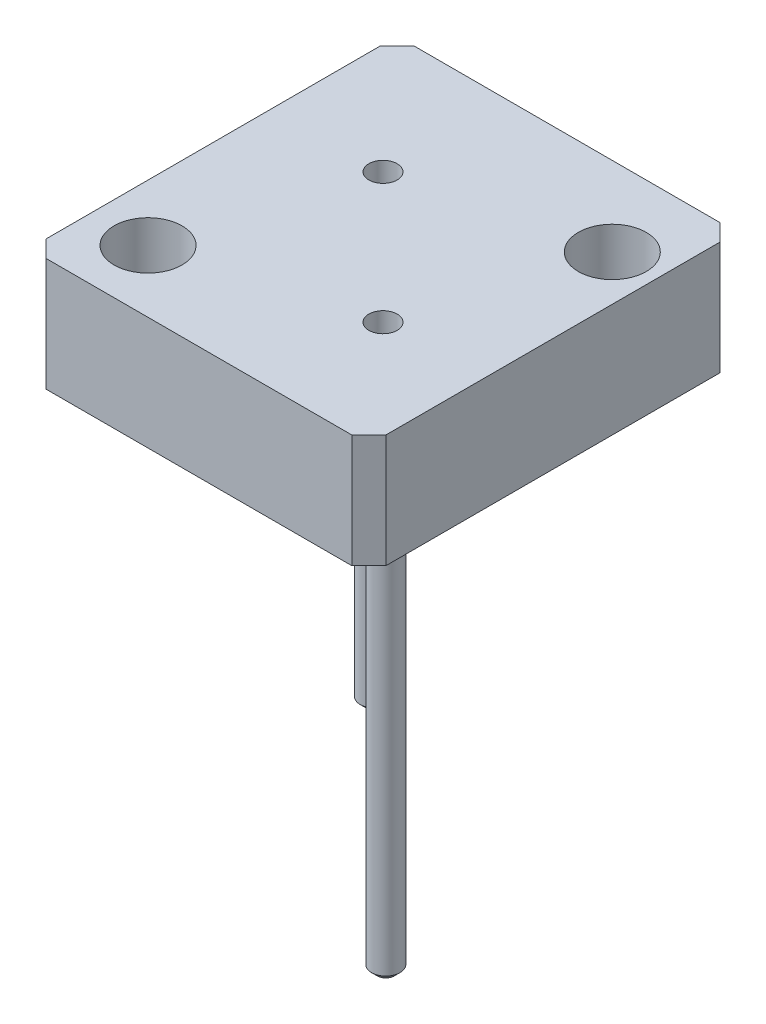
from build123d import *

# Parameters (mm, degrees)
SKETCH1_W           = 60
SKETCH1_H           = 65
BOSS_EXTRUDE1_DEPTH = 20
SKETCH2_R           = 6
CUT_EXTRUDE1_DEPTH  = 91.691785736
SKETCH2_3_R         = 2.5
CUT_EXTRUDE2_DEPTH  = 5
SKETCH2_4_R         = 2.5
BOSS_EXTRUDE2_DEPTH = 90
CHAMFER1_SIZE       = 1
CHAMFER2_SIZE       = 3


with BuildPart() as part:
    # Sketch1 → Boss-Extrude1 (new body)
    with BuildSketch(Plane(origin=(0, 0, 0), x_dir=(1, 0, 0), z_dir=(0, 1, 0))):
        with Locations((30, 32.5)):
            Rectangle(SKETCH1_W, SKETCH1_H)
    extrude(amount=BOSS_EXTRUDE1_DEPTH)

    # Sketch2 → Cut-Extrude1 (cut, through all)
    with BuildSketch(Plane(origin=(0, 20, 0), x_dir=(1, 0, 0), z_dir=(0, 1, 0))):
        with Locations((52, 51)):
            Circle(SKETCH2_R)
        with Locations((10, 11)):
            Circle(SKETCH2_R)
    extrude(amount=-CUT_EXTRUDE1_DEPTH, mode=Mode.SUBTRACT)

    # Sketch2_3 → Cut-Extrude2 (cut)
    with BuildSketch(Plane(origin=(0, 20, 0), x_dir=(1, 0, 0), z_dir=(0, 1, 0))):
        with Locations((19.5, 43)):
            Circle(SKETCH2_3_R)
        with Locations((42.5, 20)):
            Circle(SKETCH2_3_R)
    extrude(amount=-CUT_EXTRUDE2_DEPTH, mode=Mode.SUBTRACT)

    # Sketch2_4 → Boss-Extrude2 (add)
    with BuildSketch(Plane(origin=(0, 20, 0), x_dir=(1, 0, 0), z_dir=(0, 1, 0))):
        with Locations((52, 11)):
            Circle(SKETCH2_4_R)
        with Locations((10, 51)):
            Circle(SKETCH2_4_R)
    extrude(amount=-BOSS_EXTRUDE2_DEPTH)

    # Chamfer1
    chamfer1_edges = [part.edges().sort_by_distance(p)[0] for p in [
        (49.5, -70, -11),
        (7.5, -70, -51),
    ]]
    chamfer(chamfer1_edges, length=CHAMFER1_SIZE)

    # Chamfer2
    chamfer2_edges = [part.edges().sort_by_distance(p)[0] for p in [
        (60, 10, -65),
        (60, 10, 0),
        (0, 10, 0),
        (0, 10, -65),
    ]]
    chamfer(chamfer2_edges, length=CHAMFER2_SIZE)


solid = part.part
